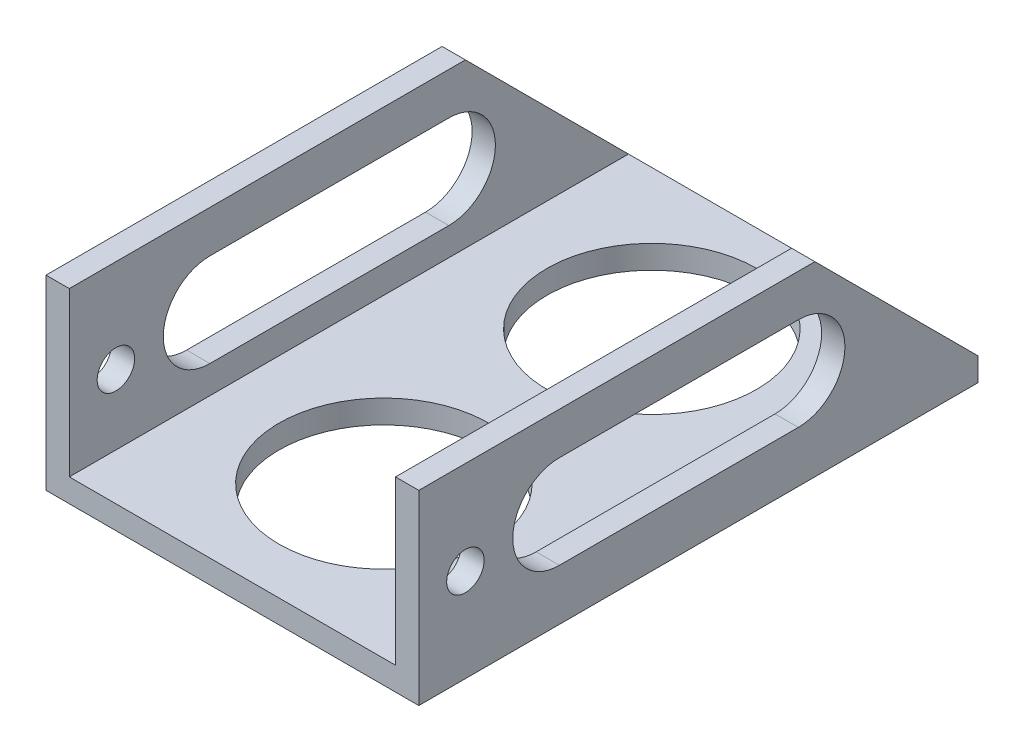
from build123d import *

# Parameters (mm, degrees)
BOSS_EXTRUDE1_DEPTH     = 76.2
CUT_EXTRUDE1_REACH      = 27.4
SKETCH2_R               = 14.2875
SKETCH3_R               = 2.5527
CUT_EXTRUDE2_DEPTH      = 51.8
CUT_EXTRUDE3_DEPTH      = 48.625
CUT_EXTRUDE3_DEPTH_BACK = 4.175
CUT_EXTRUDE4_REACH      = 5.175
SKETCH5_R               = 14.2875
CUT_EXTRUDE5_DEPTH      = 48.625
CUT_EXTRUDE5_DEPTH_BACK = 4.175


with BuildPart() as part:
    # Sketch1 → Boss-Extrude1 (new body)
    with BuildSketch(Plane.XY):
        Polygon((3.175, 3.175), (3.175, 25.4), (0, 25.4), (0, 0), (50.8, 0), (50.8, 25.4), (47.625, 25.4), (47.625, 3.175), align=None)
    extrude(amount=BOSS_EXTRUDE1_DEPTH)

    # Sketch2 → Cut-Extrude1 (cut, up to next)
    with BuildSketch(Plane.XZ, mode=Mode.PRIVATE) as cut_extrude1_sk1:
        with Locations((25.4, 19.05)):
            Circle(SKETCH2_R)
    cut_extrude1_tool1 = extrude(cut_extrude1_sk1.sketch, amount=-CUT_EXTRUDE1_REACH, mode=Mode.PRIVATE) & part.part
    add(cut_extrude1_tool1.solids().sort_by_distance((25.4, 0, 19.05))[0], mode=Mode.SUBTRACT)

    # Sketch3 → Cut-Extrude2 (cut, through all)
    with BuildSketch(Plane.ZY):
        with Locations((69.85, 12.7)):
            Circle(SKETCH3_R)
    extrude(amount=-CUT_EXTRUDE2_DEPTH, mode=Mode.SUBTRACT)

    # Sketch4 → Cut-Extrude3 (cut, two sides)
    with BuildSketch(Plane.ZY.offset(-47.625)) as cut_extrude3_sk:
        Polygon((0, 3.175), (22.225, 25.4), (0, 25.4), align=None)
    extrude(amount=CUT_EXTRUDE3_DEPTH, mode=Mode.SUBTRACT)
    extrude(cut_extrude3_sk.sketch, amount=-CUT_EXTRUDE3_DEPTH_BACK, mode=Mode.SUBTRACT)

    # Sketch5 → Cut-Extrude4 (cut, up to next)
    with BuildSketch(Plane(origin=(0, 3.175, 0), x_dir=(1, 0, 0), z_dir=(0, 1, 0)), mode=Mode.PRIVATE) as cut_extrude4_sk1:
        with Locations((25.4, -55.5625)):
            Circle(SKETCH5_R)
    cut_extrude4_tool1 = extrude(cut_extrude4_sk1.sketch, amount=-CUT_EXTRUDE4_REACH, mode=Mode.PRIVATE) & part.part
    add(cut_extrude4_tool1.solids().sort_by_distance((25.4, 3.175, 55.5625))[0], mode=Mode.SUBTRACT)

    # Sketch6 → Cut-Extrude5 (cut, two sides)
    with BuildSketch(Plane.ZY.offset(-47.625)) as cut_extrude5_sk:
        with BuildLine():
            Line((24.485892943, 19.673757433), (57.04010233, 19.673757433))
            ThreePointArc((57.04010233, 19.673757433), (63.39010233, 13.323757433), (57.04010233, 6.973757433))
            Line((57.04010233, 6.973757433), (24.485892943, 6.973757433))
            ThreePointArc((24.485892943, 6.973757433), (18.135892943, 13.323757433), (24.485892943, 19.673757433))
        make_face()
    extrude(amount=CUT_EXTRUDE5_DEPTH, mode=Mode.SUBTRACT)
    extrude(cut_extrude5_sk.sketch, amount=-CUT_EXTRUDE5_DEPTH_BACK, mode=Mode.SUBTRACT)


solid = part.part
